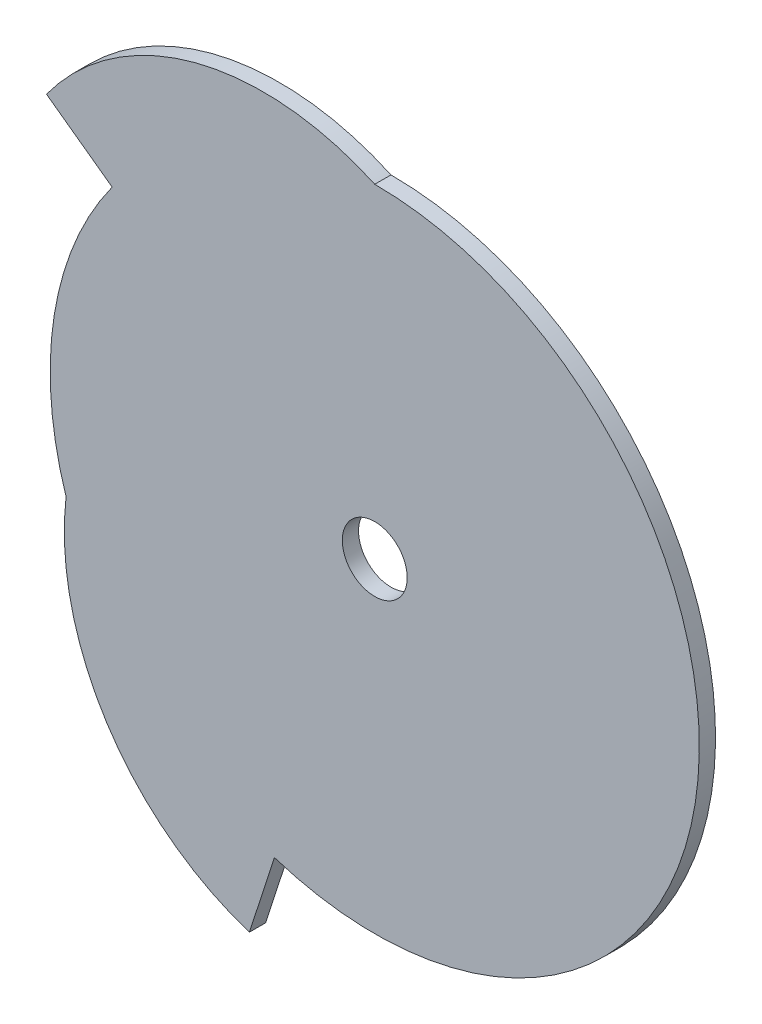
from build123d import *

# Parameters (mm, degrees)
SALIENTE_EXTRUIR1_DEPTH = 3
CROQUIS2_R              = 6
CORTAR_EXTRUIR1_DEPTH   = 3


with BuildPart() as part:
    # Croquis1 → Saliente-Extruir1 (new body)
    with BuildSketch(Plane.XY):
        with BuildLine():
            Line((-48.541019662, 35.267115138), (-60.676274578, 44.083893922))
            ThreePointArc((-60.676274578, 44.083893922), (-33.17983972, 62.875244761), (0, 60))
            ThreePointArc((0, 60), (59.261300436, -9.386067902), (-18.541019662, -57.063390978))
            Line((-18.541019662, -57.063390978), (-23.176274578, -71.329238722))
            ThreePointArc((-23.176274578, -71.329238722), (-49.544776899, -50.985421932), (-57.063390978, -18.541019662))
            ThreePointArc((-57.063390978, -18.541019662), (-59.261300436, 9.386067902), (-48.541019662, 35.267115138))
        make_face()
    extrude(amount=SALIENTE_EXTRUIR1_DEPTH)

    # Croquis2 → Cortar-Extruir1 (cut)
    with BuildSketch(Plane.XY.offset(3)):
        Circle(CROQUIS2_R)
    extrude(amount=-CORTAR_EXTRUIR1_DEPTH, mode=Mode.SUBTRACT)


solid = part.part
